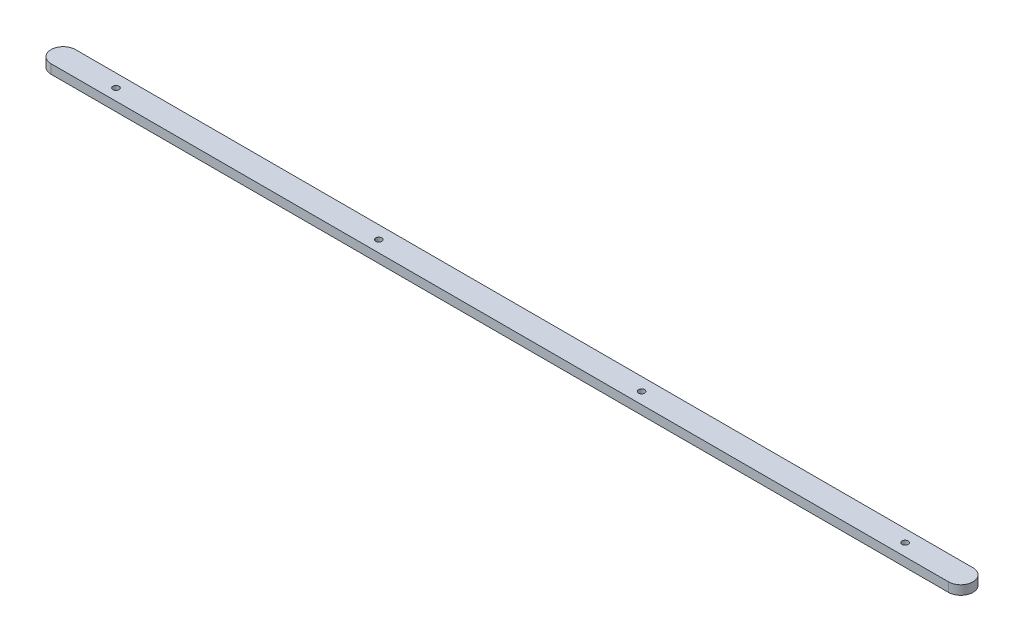
from build123d import *

# Parameters (mm, degrees)
SKETCH1_R           = 1
BOSS_EXTRUDE1_DEPTH = 3


with BuildPart() as part:
    # Sketch1 → Boss-Extrude1 (new body)
    with BuildSketch(Plane(origin=(0, 0, 0), x_dir=(1, 0, 0), z_dir=(0, 1, 0))):
        with BuildLine():
            Line((-146.345646623, -7.360189179), (147.353703377, -7.360189179))
            ThreePointArc((147.353703377, -7.360189179), (150.182130502, -6.188616304), (151.353703377, -3.360189179))
            ThreePointArc((151.353703377, -3.360189179), (150.182130502, -0.531762055), (147.353703377, 0.639810821))
            Line((147.353703377, 0.639810821), (-146.345646623, 0.639810821))
            ThreePointArc((-146.345646623, 0.639810821), (-149.174073748, -0.531762055), (-150.345646623, -3.360189179))
            ThreePointArc((-150.345646623, -3.360189179), (-149.174073748, -6.188616304), (-146.345646623, -7.360189179))
        make_face()
        with Locations((-128.845646623, -3.610189179)):
            Circle(SKETCH1_R, mode=Mode.SUBTRACT)
        with Locations((-42.845646623, -3.610189179)):
            Circle(SKETCH1_R, mode=Mode.SUBTRACT)
        with Locations((43.154353377, -3.610189179)):
            Circle(SKETCH1_R, mode=Mode.SUBTRACT)
        with Locations((129.154353377, -3.360189179)):
            Circle(SKETCH1_R, mode=Mode.SUBTRACT)
    extrude(amount=BOSS_EXTRUDE1_DEPTH)


solid = part.part
